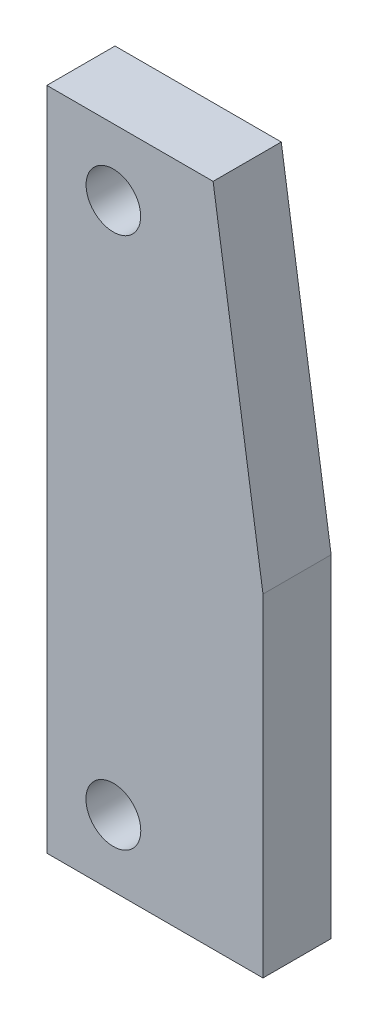
from build123d import *

# Parameters (mm, degrees)
SKETCH1_R           = 1.65
SKETCH1_R_2         = 1.642532795
BOSS_EXTRUDE1_DEPTH = 4.1


with BuildPart() as part:
    # Sketch1 → Boss-Extrude1 (new body)
    with BuildSketch(Plane.XY):
        Polygon((1, 2.483732861), (1, 42.483732861), (11, 42.483732861), (14, 22.483732861), (14, 2.483732861), align=None)
        with Locations((5, 6.483732861)):
            Circle(SKETCH1_R, mode=Mode.SUBTRACT)
        with Locations((5, 38.483732861)):
            Circle(SKETCH1_R_2, mode=Mode.SUBTRACT)
    extrude(amount=BOSS_EXTRUDE1_DEPTH)


solid = part.part
